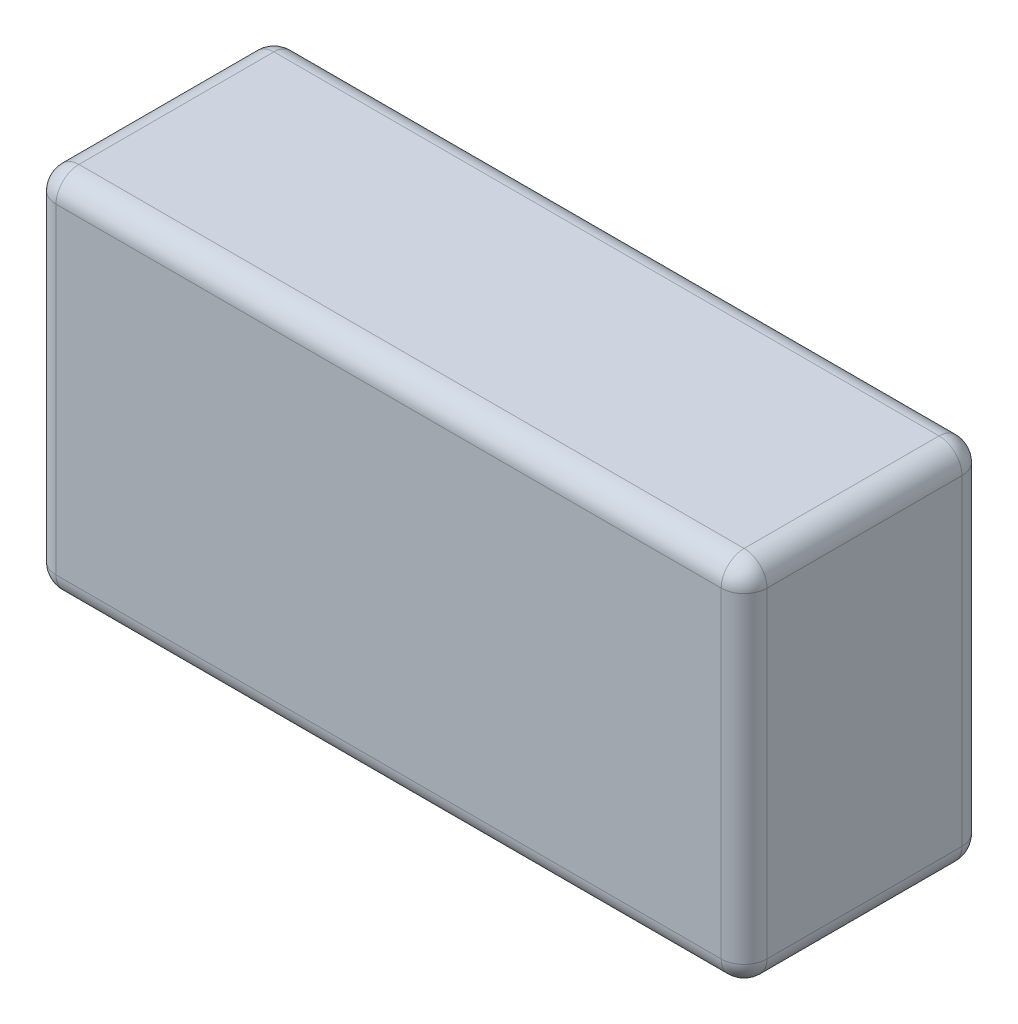
from build123d import *

# Parameters (mm, degrees)
ESBO_O1_W                = 62
ESBO_O1_H                = 32
RESSALTO_EXTRUS_O1_DEPTH = 21
FILETE1_R                = 2


with BuildPart() as part:
    # Esboço1 → Ressalto-extrusão1 (new body)
    with BuildSketch(Plane.XY):
        with Locations((6.085348506, -5.196301565)):
            Rectangle(ESBO_O1_W, ESBO_O1_H)
    extrude(amount=RESSALTO_EXTRUS_O1_DEPTH)

    # Filete1
    filete1_edges = [part.edges().sort_by_distance(p)[0] for p in [
        (37.085348506, -5.196301565, 21),
        (6.085348506, 10.803698435, 21),
        (-24.914651494, -5.196301565, 21),
        (6.085348506, 10.803698435, 0),
        (37.085348506, -5.196301565, 0),
        (6.085348506, -21.196301565, 0),
        (-24.914651494, -5.196301565, 0),
        (6.085348506, -21.196301565, 21),
        (-24.914651494, 10.803698435, 10.5),
        (37.085348506, 10.803698435, 10.5),
        (37.085348506, -21.196301565, 10.5),
        (-24.914651494, -21.196301565, 10.5),
    ]]
    fillet(filete1_edges, radius=FILETE1_R)


solid = part.part
